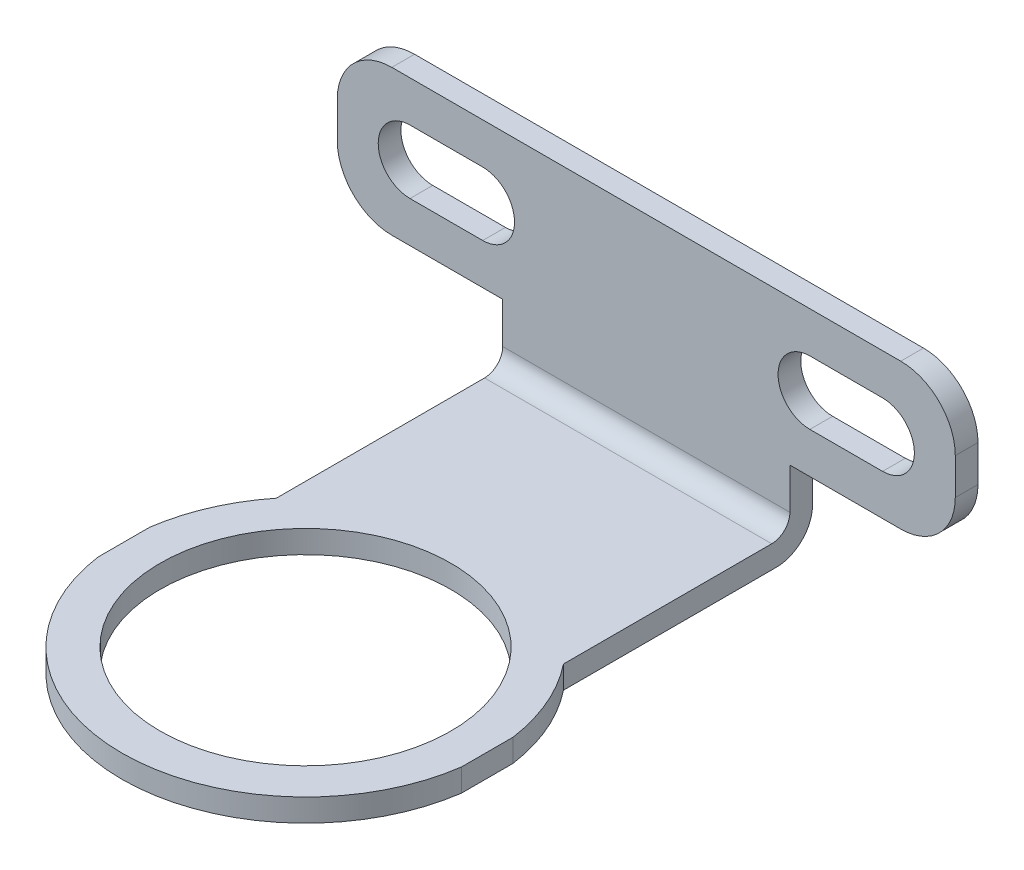
from build123d import *

# Parameters (mm, degrees)
BOSS_EXTRUDE1_DEPTH       = 2.5
CUT_EXTRUDE1_DEPTH        = 3.5
CUT_EXTRUDE2_DEPTH        = 3.5
SKETCH4_W                 = 31.6
SKETCH4_H                 = 2.5
BOSS_EXTRUDE2_DEPTH       = 22.5
SKETCH5_W                 = 2.5
SKETCH5_H                 = 16
BOSS_EXTRUDE3_DEPTH       = 18.2
SKETCH6_W                 = 2.5
SKETCH6_H                 = 16
BOSS_EXTRUDE4_DEPTH       = 18.2
CUT_EXTRUDE3_DEPTH        = 3.5
CUT_EXTRUDE4_DEPTH        = 61.2
M27_CLEARANCE_HOLE1_D     = 32
M27_CLEARANCE_HOLE1_DEPTH = 2.5
FILLET1_R                 = 2
FILLET2_R                 = 4
FILLET3_R                 = 6


with BuildPart() as part:
    # Sketch1 → Boss-Extrude1 (new body)
    with BuildSketch(Plane(origin=(0, 2.5, 0), x_dir=(1, 0, 0), z_dir=(0, 1, 0))):
        with BuildLine():
            Line((20, -42.835489376), (20, 0))
            Line((20, 0), (-20, 0))
            Line((-20, 0), (-20, -42.835489376))
            ThreePointArc((-20, -42.835489376), (0, -60.2), (20, -42.835489376))
        make_face()
    extrude(amount=-BOSS_EXTRUDE1_DEPTH)

    # Sketch2 → Cut-Extrude1 (cut, through all)
    with BuildSketch(Plane.XZ):
        with BuildLine():
            Line((-15.8, 0), (-15.8, 27.414293822))
            ThreePointArc((-15.8, 27.414293822), (-18.551999405, 32.008547186), (-20, 37.164510624))
            Line((-20, 37.164510624), (-20, 0))
            Line((-20, 0), (-15.8, 0))
        make_face()
    extrude(amount=-CUT_EXTRUDE1_DEPTH, mode=Mode.SUBTRACT)

    # Sketch3 → Cut-Extrude2 (cut, through all)
    with BuildSketch(Plane.XZ):
        with BuildLine():
            Line((20, 0), (20, 37.164510624))
            ThreePointArc((20, 37.164510624), (18.551999405, 32.008547186), (15.8, 27.414293822))
            Line((15.8, 27.414293822), (15.8, 0))
            Line((15.8, 0), (20, 0))
        make_face()
    extrude(amount=-CUT_EXTRUDE2_DEPTH, mode=Mode.SUBTRACT)

    # Sketch4 → Boss-Extrude2 (add)
    with BuildSketch(Plane(origin=(0, 2.5, 0), x_dir=(-1, 0, 0), z_dir=(0, 1, 0))):
        with Locations((0, 1.25)):
            Rectangle(SKETCH4_W, SKETCH4_H)
    extrude(amount=BOSS_EXTRUDE2_DEPTH)

    # Sketch5 → Boss-Extrude3 (add)
    with BuildSketch(Plane(origin=(15.8, 0, 0), x_dir=(0, 0, -1), z_dir=(1, 0, 0))):
        with Locations((-1.25, 17)):
            Rectangle(SKETCH5_W, SKETCH5_H)
    extrude(amount=BOSS_EXTRUDE3_DEPTH)

    # Sketch6 → Boss-Extrude4 (add)
    with BuildSketch(Plane.ZY.offset(15.8)):
        with Locations((1.25, 17)):
            Rectangle(SKETCH6_W, SKETCH6_H)
    extrude(amount=BOSS_EXTRUDE4_DEPTH)

    # Sketch7 → Cut-Extrude3 (cut, through all)
    with BuildSketch(Plane.XY.offset(2.5)):
        with BuildLine():
            Line((26, 20.5), (18, 20.5))
            ThreePointArc((18, 20.5), (14.5, 17), (18, 13.5))
            Line((18, 13.5), (26, 13.5))
            ThreePointArc((26, 13.5), (29.5, 17), (26, 20.5))
        make_face()
    extrude(amount=-CUT_EXTRUDE3_DEPTH, mode=Mode.SUBTRACT)

    # Sketch8 → Cut-Extrude4 (cut, through all)
    with BuildSketch(Plane(origin=(0, 0, 0), x_dir=(-1, 0, 0), z_dir=(0, 0, -1))):
        with BuildLine():
            Line((26, 20.5), (18, 20.5))
            ThreePointArc((18, 20.5), (14.5, 17), (18, 13.5))
            Line((18, 13.5), (26, 13.5))
            ThreePointArc((26, 13.5), (29.5, 17), (26, 20.5))
        make_face()
    extrude(amount=-CUT_EXTRUDE4_DEPTH, mode=Mode.SUBTRACT)

    # M27 Clearance Hole1
    with Locations(Plane(origin=(0, 2.5, 0), x_dir=(1, 0, 0), z_dir=(0, 1, 0))):
        with Locations((0, -40)):
            Hole(M27_CLEARANCE_HOLE1_D / 2, depth=M27_CLEARANCE_HOLE1_DEPTH)

    # Fillet1
    fillet1_edges = [part.edges().sort_by_distance(p)[0] for p in [
        (0, 2.5, 2.5),
    ]]
    fillet(fillet1_edges, radius=FILLET1_R)

    # Fillet2
    fillet2_edges = [part.edges().sort_by_distance(p)[0] for p in [
        (0, 0, 0),
    ]]
    fillet(fillet2_edges, radius=FILLET2_R)

    # Fillet3
    fillet3_edges = [part.edges().sort_by_distance(p)[0] for p in [
        (34, 25, 1.25),
        (34, 9, 1.25),
        (-34, 9, 1.25),
        (-34, 25, 1.25),
    ]]
    fillet(fillet3_edges, radius=FILLET3_R)


solid = part.part
